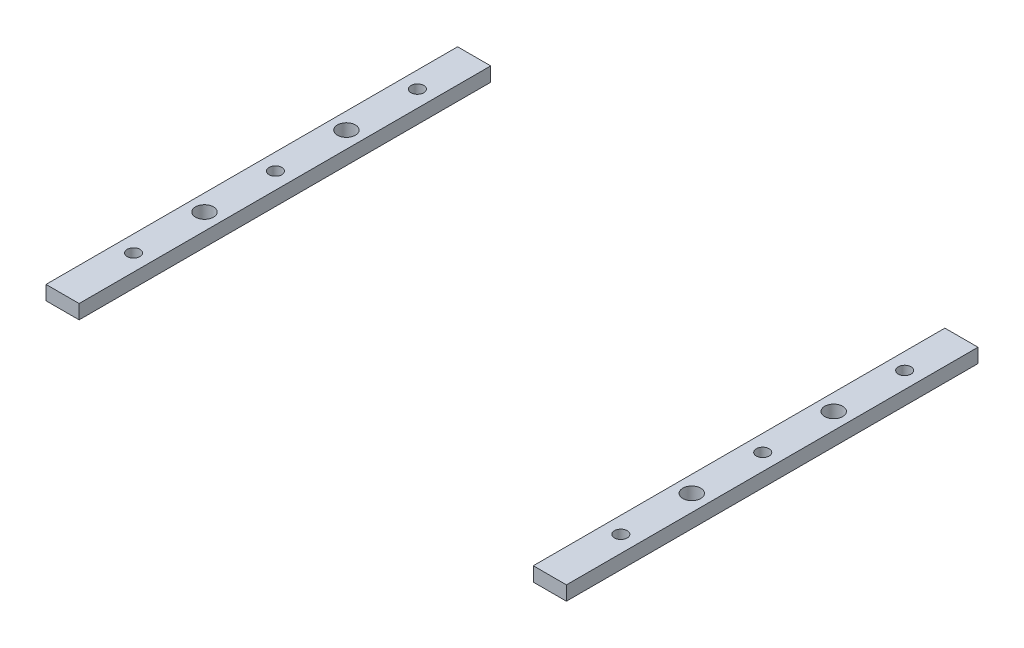
from build123d import *

# Parameters (mm, degrees)
SKETCH1_W            = 7
SKETCH1_H            = 87
SKETCH1_R            = 1.35
SPACER_RAILS_DEPTH   = 3
SPACER_RAILS_2_DEPTH = 3
SKETCH2_R            = 1.9
CUT_EXTRUDE2_DEPTH   = 141.278294829


with BuildPart() as part:
    # Sketch1 → spacer-rails (new body)
    with BuildSketch(Plane(origin=(0, 0, 0), x_dir=(1, 0, 0), z_dir=(0, 1, 0))):
        with Locations((3.5, 43.5)):
            Rectangle(SKETCH1_W, SKETCH1_H)
        with Locations((3.5, 15)):
            Circle(SKETCH1_R, mode=Mode.SUBTRACT)
        with Locations((3.5, 30)):
            Circle(SKETCH1_R, mode=Mode.SUBTRACT)
        with Locations((3.5, 45)):
            Circle(SKETCH1_R, mode=Mode.SUBTRACT)
        with Locations((3.5, 60)):
            Circle(SKETCH1_R, mode=Mode.SUBTRACT)
        with Locations((3.5, 75)):
            Circle(SKETCH1_R, mode=Mode.SUBTRACT)
    extrude(amount=SPACER_RAILS_DEPTH)


with BuildPart() as body_2:
    # Sketch1 → spacer-rails 2 (new body)
    with BuildSketch(Plane(origin=(0, 0, 0), x_dir=(1, 0, 0), z_dir=(0, 1, 0))):
        with Locations((106.5, 43.5)):
            Rectangle(SKETCH1_W, SKETCH1_H)
        with Locations((106.5, 15)):
            Circle(SKETCH1_R, mode=Mode.SUBTRACT)
        with Locations((106.5, 30)):
            Circle(SKETCH1_R, mode=Mode.SUBTRACT)
        with Locations((106.5, 75)):
            Circle(SKETCH1_R, mode=Mode.SUBTRACT)
        with Locations((106.5, 60)):
            Circle(SKETCH1_R, mode=Mode.SUBTRACT)
        with Locations((106.5, 45)):
            Circle(SKETCH1_R, mode=Mode.SUBTRACT)
    extrude(amount=SPACER_RAILS_2_DEPTH)


with BuildPart() as cut_extrude2_tool:
    # Sketch2 → Cut-Extrude2 (new, through all)
    with BuildSketch(Plane.XZ):
        with Locations((3.5, -30)):
            Circle(SKETCH2_R)
        with Locations((106.5, -30)):
            Circle(SKETCH2_R)
        with Locations((106.5, -60)):
            Circle(SKETCH2_R)
        with Locations((3.5, -60)):
            Circle(SKETCH2_R)
    extrude(amount=-CUT_EXTRUDE2_DEPTH)


with BuildPart() as part_1:
    add(part.part)

    # Cut-Extrude2: cut by cut_extrude2_tool
    add(cut_extrude2_tool.part, mode=Mode.SUBTRACT)


with BuildPart() as body_2_1:
    add(body_2.part)

    # Cut-Extrude2: cut by cut_extrude2_tool
    add(cut_extrude2_tool.part, mode=Mode.SUBTRACT)


solid = Compound([part_1.part, body_2_1.part])
